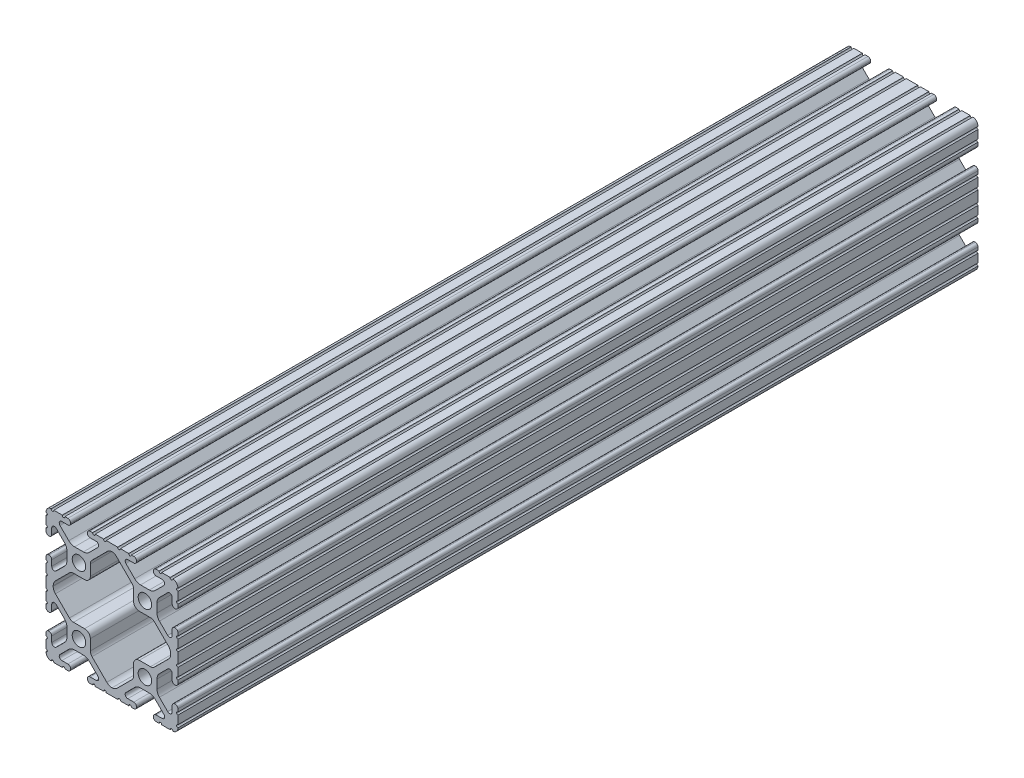
from build123d import *

# Parameters (mm, degrees)
SKETCH1_R      = 2.6035
EXTRUDE1_DEPTH = 308.102


with BuildPart() as part:
    # Sketch1 → Extrude1 (new body)
    with BuildSketch(Plane.XY):
        with BuildLine():
            Line((-2.210122516, -25.4), (2.210122516, -25.4))
            ThreePointArc((2.210122516, -25.4), (2.712319242, -24.815433371), (3.214515968, -25.4))
            Line((3.214515968, -25.4), (6.453532688, -25.4))
            ThreePointArc((6.453532688, -25.4), (6.955729414, -24.815433371), (7.45792614, -25.4))
            Line((7.45792614, -25.4), (8.405130016, -25.4))
            ThreePointArc((8.405130016, -25.4), (9.151169169, -25.100362415), (9.461500022, -24.358707602))
            Line((9.461500022, -24.358707602), (9.4615, -24.231492399))
            ThreePointArc((9.4615, -24.231492399), (9.151169155, -23.489837593), (8.405130016, -23.1902))
            Line((8.405130016, -23.1902), (6.087754002, -23.1902))
            ThreePointArc((6.087754002, -23.1902), (5.173448619, -22.579280675), (5.387974958, -21.500783941))
            Line((5.387974958, -21.500783941), (8.763022929, -18.12573597))
            ThreePointArc((8.763022929, -18.12573597), (9.793067061, -17.437482484), (11.008086959, -17.1958))
            Line((11.008086959, -17.1958), (14.391913041, -17.1958))
            ThreePointArc((14.391913041, -17.1958), (15.606932939, -17.437482484), (16.636977071, -18.12573597))
            Line((16.636977071, -18.12573597), (20.012025042, -21.500783941))
            ThreePointArc((20.012025042, -21.500783941), (20.223734168, -22.586011733), (19.297652818, -23.190092399))
            Line((19.297652818, -23.190092399), (16.9799, -23.190092399))
            ThreePointArc((16.9799, -23.190092399), (16.243518998, -23.495111397), (15.9385, -24.231492399))
            Line((15.9385, -24.231492399), (15.9385, -24.358492399))
            ThreePointArc((15.9385, -24.358492399), (16.248754204, -25.100286874), (16.994869984, -25.4))
            Line((16.994869984, -25.4), (18.134015685, -25.4))
            ThreePointArc((18.134015685, -25.4), (18.636212411, -24.815433371), (19.138409137, -25.4))
            Line((19.138409137, -25.4), (20.1295, -25.4))
            Line((20.1295, -25.4), (22.413213213, -25.4))
            ThreePointArc((22.413213213, -25.4), (22.915409939, -24.815433371), (23.417606664, -25.4))
            Line((23.417606664, -25.4), (23.450078724, -25.4))
            ThreePointArc((23.450078724, -25.4), (24.838729535, -24.730064765), (25.4, -23.294049529))
            Line((25.4, -23.294049529), (25.4, -23.268649529))
            ThreePointArc((25.4, -23.268649529), (24.892, -22.760649529), (25.4, -22.252649529))
            Line((25.4, -22.252649529), (25.4, -21.160449529))
            Line((25.4, -21.160449529), (25.4, -19.025239356))
            ThreePointArc((25.4, -19.025239356), (24.892, -18.517239356), (25.4, -18.009239356))
            Line((25.4, -18.009239356), (25.4, -16.91604181))
            ThreePointArc((25.4, -16.91604181), (25.094981002, -16.179660808), (24.3586, -15.87464181))
            Line((24.3586, -15.87464181), (24.2316, -15.87464181))
            ThreePointArc((24.2316, -15.87464181), (23.495218998, -16.179660808), (23.1902, -16.91604181))
            Line((23.1902, -16.91604181), (23.1902, -19.100988789))
            ThreePointArc((23.1902, -19.100988789), (22.563006367, -20.039650394), (21.45577951, -19.819409279))
            Line((21.45577951, -19.819409279), (18.27813597, -16.641765738))
            ThreePointArc((18.27813597, -16.641765738), (17.589882484, -15.611721606), (17.3482, -14.396701708))
            Line((17.3482, -14.396701708), (17.3482, -11.003495043))
            ThreePointArc((17.3482, -11.003495043), (17.590610762, -9.786718415), (18.280827, -8.755743204))
            Line((18.280827, -8.755743204), (21.45664064, -5.587529241))
            ThreePointArc((21.45664064, -5.587529241), (22.563568521, -5.368381274), (23.1902, -6.30680983))
            Line((23.1902, -6.30680983), (23.1902, -8.48395819))
            ThreePointArc((23.1902, -8.48395819), (23.495218998, -9.220339192), (24.2316, -9.52535819))
            Line((24.2316, -9.52535819), (24.3586, -9.52535819))
            ThreePointArc((24.3586, -9.52535819), (25.094981002, -9.220339192), (25.4, -8.48395819))
            Line((25.4, -8.48395819), (25.4, -7.327686685))
            ThreePointArc((25.4, -7.327686685), (24.892, -6.819686685), (25.4, -6.311686685))
            Line((25.4, -6.311686685), (25.4, -3.084276513))
            ThreePointArc((25.4, -3.084276513), (24.892, -2.576276513), (25.4, -2.068276513))
            Line((25.4, -2.068276513), (25.4, 2.068276513))
            ThreePointArc((25.4, 2.068276513), (24.892, 2.576276513), (25.4, 3.084276513))
            Line((25.4, 3.084276513), (25.4, 6.311686685))
            ThreePointArc((25.4, 6.311686685), (24.892, 6.819686685), (25.4, 7.327686685))
            Line((25.4, 7.327686685), (25.4, 8.48395819))
            ThreePointArc((25.4, 8.48395819), (25.094981002, 9.220339192), (24.3586, 9.52535819))
            Line((24.3586, 9.52535819), (24.2316, 9.52535819))
            ThreePointArc((24.2316, 9.52535819), (23.495218998, 9.220339192), (23.1902, 8.48395819))
            Line((23.1902, 8.48395819), (23.1902, 6.30680983))
            ThreePointArc((23.1902, 6.30680983), (22.563568521, 5.368381274), (21.45664064, 5.587529241))
            Line((21.45664064, 5.587529241), (18.280827, 8.755743204))
            ThreePointArc((18.280827, 8.755743204), (17.590610762, 9.786718415), (17.3482, 11.003495043))
            Line((17.3482, 11.003495043), (17.3482, 14.396701708))
            ThreePointArc((17.3482, 14.396701708), (17.589882484, 15.611721606), (18.27813597, 16.641765738))
            Line((18.27813597, 16.641765738), (21.45577951, 19.819409279))
            ThreePointArc((21.45577951, 19.819409279), (22.563006367, 20.039650394), (23.1902, 19.100988789))
            Line((23.1902, 19.100988789), (23.1902, 16.91604181))
            ThreePointArc((23.1902, 16.91604181), (23.495218998, 16.179660808), (24.2316, 15.87464181))
            Line((24.2316, 15.87464181), (24.3586, 15.87464181))
            ThreePointArc((24.3586, 15.87464181), (25.094981002, 16.179660808), (25.4, 16.91604181))
            Line((25.4, 16.91604181), (25.4, 18.009239356))
            ThreePointArc((25.4, 18.009239356), (24.892, 18.517239356), (25.4, 19.025239356))
            Line((25.4, 19.025239356), (25.4, 21.160449529))
            Line((25.4, 21.160449529), (25.4, 22.252649529))
            ThreePointArc((25.4, 22.252649529), (24.892, 22.760649529), (25.4, 23.268649529))
            Line((25.4, 23.268649529), (25.4, 23.294049529))
            ThreePointArc((25.4, 23.294049529), (24.838729535, 24.730064765), (23.450078724, 25.4))
            Line((23.450078724, 25.4), (23.417606664, 25.4))
            ThreePointArc((23.417606664, 25.4), (22.915409939, 24.815433371), (22.413213213, 25.4))
            Line((22.413213213, 25.4), (20.1295, 25.4))
            Line((20.1295, 25.4), (19.138409137, 25.4))
            ThreePointArc((19.138409137, 25.4), (18.636212411, 24.815433371), (18.134015685, 25.4))
            Line((18.134015685, 25.4), (16.994869984, 25.4))
            ThreePointArc((16.994869984, 25.4), (16.248754204, 25.100286874), (15.9385, 24.358492399))
            Line((15.9385, 24.358492399), (15.9385, 24.231492399))
            ThreePointArc((15.9385, 24.231492399), (16.243518998, 23.495111397), (16.9799, 23.190092399))
            Line((16.9799, 23.190092399), (19.297652818, 23.190092399))
            ThreePointArc((19.297652818, 23.190092399), (20.223734168, 22.586011733), (20.012025042, 21.500783941))
            Line((20.012025042, 21.500783941), (16.636977071, 18.12573597))
            ThreePointArc((16.636977071, 18.12573597), (15.606932939, 17.437482484), (14.391913041, 17.1958))
            Line((14.391913041, 17.1958), (11.008086959, 17.1958))
            ThreePointArc((11.008086959, 17.1958), (9.793067061, 17.437482484), (8.763022929, 18.12573597))
            Line((8.763022929, 18.12573597), (5.387974958, 21.500783941))
            ThreePointArc((5.387974958, 21.500783941), (5.173448619, 22.579280675), (6.087754002, 23.1902))
            Line((6.087754002, 23.1902), (8.405130016, 23.1902))
            ThreePointArc((8.405130016, 23.1902), (9.151169155, 23.489837593), (9.4615, 24.231492399))
            Line((9.4615, 24.231492399), (9.461500022, 24.358707602))
            ThreePointArc((9.461500022, 24.358707602), (9.151169169, 25.100362415), (8.405130016, 25.4))
            Line((8.405130016, 25.4), (7.45792614, 25.4))
            ThreePointArc((7.45792614, 25.4), (6.955729414, 24.815433371), (6.453532688, 25.4))
            Line((6.453532688, 25.4), (3.214515968, 25.4))
            ThreePointArc((3.214515968, 25.4), (2.712319242, 24.815433371), (2.210122516, 25.4))
            Line((2.210122516, 25.4), (-2.210122516, 25.4))
            ThreePointArc((-2.210122516, 25.4), (-2.712319242, 24.815433371), (-3.214515968, 25.4))
            Line((-3.214515968, 25.4), (-5.2705, 25.4))
            Line((-5.2705, 25.4), (-6.453532688, 25.4))
            ThreePointArc((-6.453532688, 25.4), (-6.955729414, 24.815433371), (-7.45792614, 25.4))
            Line((-7.45792614, 25.4), (-8.405130016, 25.4))
            ThreePointArc((-8.405130016, 25.4), (-9.151169169, 25.100362415), (-9.461500022, 24.358707602))
            Line((-9.461500022, 24.358707602), (-9.4615, 24.231492399))
            ThreePointArc((-9.4615, 24.231492399), (-9.151169155, 23.489837593), (-8.405130016, 23.1902))
            Line((-8.405130016, 23.1902), (-6.087754002, 23.1902))
            ThreePointArc((-6.087754002, 23.1902), (-5.173448619, 22.579280675), (-5.387974958, 21.500783941))
            Line((-5.387974958, 21.500783941), (-8.763022929, 18.12573597))
            ThreePointArc((-8.763022929, 18.12573597), (-9.793067061, 17.437482484), (-11.008086959, 17.1958))
            Line((-11.008086959, 17.1958), (-14.391913041, 17.1958))
            ThreePointArc((-14.391913041, 17.1958), (-15.606932939, 17.437482484), (-16.636977071, 18.12573597))
            Line((-16.636977071, 18.12573597), (-20.012025042, 21.500783941))
            ThreePointArc((-20.012025042, 21.500783941), (-20.223734168, 22.586011733), (-19.297652818, 23.190092399))
            Line((-19.297652818, 23.190092399), (-16.9799, 23.190092399))
            ThreePointArc((-16.9799, 23.190092399), (-16.243518998, 23.495111397), (-15.9385, 24.231492399))
            Line((-15.9385, 24.231492399), (-15.9385, 24.358492399))
            ThreePointArc((-15.9385, 24.358492399), (-16.248754204, 25.100286874), (-16.994869984, 25.4))
            Line((-16.994869984, 25.4), (-18.134015685, 25.4))
            ThreePointArc((-18.134015685, 25.4), (-18.636212411, 24.815433371), (-19.138409137, 25.4))
            Line((-19.138409137, 25.4), (-20.1295, 25.4))
            Line((-20.1295, 25.4), (-22.413213213, 25.4))
            ThreePointArc((-22.413213213, 25.4), (-22.915409939, 24.815433371), (-23.417606664, 25.4))
            Line((-23.417606664, 25.4), (-23.450078724, 25.4))
            ThreePointArc((-23.450078724, 25.4), (-24.838729535, 24.730064765), (-25.4, 23.294049529))
            Line((-25.4, 23.294049529), (-25.4, 23.268649529))
            ThreePointArc((-25.4, 23.268649529), (-24.892, 22.760649529), (-25.4, 22.252649529))
            Line((-25.4, 22.252649529), (-25.4, 21.160449529))
            Line((-25.4, 21.160449529), (-25.4, 19.025239356))
            ThreePointArc((-25.4, 19.025239356), (-24.892, 18.517239356), (-25.4, 18.009239356))
            Line((-25.4, 18.009239356), (-25.4, 16.91604181))
            ThreePointArc((-25.4, 16.91604181), (-25.094981002, 16.179660808), (-24.3586, 15.87464181))
            Line((-24.3586, 15.87464181), (-24.2316, 15.87464181))
            ThreePointArc((-24.2316, 15.87464181), (-23.495218998, 16.179660808), (-23.1902, 16.91604181))
            Line((-23.1902, 16.91604181), (-23.1902, 19.100988789))
            ThreePointArc((-23.1902, 19.100988789), (-22.563006367, 20.039650394), (-21.45577951, 19.819409279))
            Line((-21.45577951, 19.819409279), (-18.27813597, 16.641765738))
            ThreePointArc((-18.27813597, 16.641765738), (-17.589882484, 15.611721606), (-17.3482, 14.396701708))
            Line((-17.3482, 14.396701708), (-17.3482, 11.003495043))
            ThreePointArc((-17.3482, 11.003495043), (-17.590610762, 9.786718415), (-18.280827, 8.755743204))
            Line((-18.280827, 8.755743204), (-21.45664064, 5.587529241))
            ThreePointArc((-21.45664064, 5.587529241), (-22.563568521, 5.368381274), (-23.1902, 6.30680983))
            Line((-23.1902, 6.30680983), (-23.1902, 8.48395819))
            ThreePointArc((-23.1902, 8.48395819), (-23.495218998, 9.220339192), (-24.2316, 9.52535819))
            Line((-24.2316, 9.52535819), (-24.3586, 9.52535819))
            ThreePointArc((-24.3586, 9.52535819), (-25.094981002, 9.220339192), (-25.4, 8.48395819))
            Line((-25.4, 8.48395819), (-25.4, 7.327686685))
            ThreePointArc((-25.4, 7.327686685), (-24.892, 6.819686685), (-25.4, 6.311686685))
            Line((-25.4, 6.311686685), (-25.4, 3.084276513))
            ThreePointArc((-25.4, 3.084276513), (-24.892, 2.576276513), (-25.4, 2.068276513))
            Line((-25.4, 2.068276513), (-25.4, -2.068276513))
            ThreePointArc((-25.4, -2.068276513), (-24.892, -2.576276513), (-25.4, -3.084276513))
            Line((-25.4, -3.084276513), (-25.4, -4.176476513))
            Line((-25.4, -4.176476513), (-25.4, -6.311686685))
            ThreePointArc((-25.4, -6.311686685), (-24.892, -6.819686685), (-25.4, -7.327686685))
            Line((-25.4, -7.327686685), (-25.4, -8.48395819))
            ThreePointArc((-25.4, -8.48395819), (-25.094981002, -9.220339192), (-24.3586, -9.52535819))
            Line((-24.3586, -9.52535819), (-24.2316, -9.52535819))
            ThreePointArc((-24.2316, -9.52535819), (-23.495218998, -9.220339192), (-23.1902, -8.48395819))
            Line((-23.1902, -8.48395819), (-23.1902, -6.30680983))
            ThreePointArc((-23.1902, -6.30680983), (-22.563568521, -5.368381274), (-21.45664064, -5.587529241))
            Line((-21.45664064, -5.587529241), (-18.280827, -8.755743204))
            ThreePointArc((-18.280827, -8.755743204), (-17.590610762, -9.786718415), (-17.3482, -11.003495043))
            Line((-17.3482, -11.003495043), (-17.3482, -14.396701708))
            ThreePointArc((-17.3482, -14.396701708), (-17.589882484, -15.611721606), (-18.27813597, -16.641765738))
            Line((-18.27813597, -16.641765738), (-21.45577951, -19.819409279))
            ThreePointArc((-21.45577951, -19.819409279), (-22.563006367, -20.039650394), (-23.1902, -19.100988789))
            Line((-23.1902, -19.100988789), (-23.1902, -16.91604181))
            ThreePointArc((-23.1902, -16.91604181), (-23.495218998, -16.179660808), (-24.2316, -15.87464181))
            Line((-24.2316, -15.87464181), (-24.3586, -15.87464181))
            ThreePointArc((-24.3586, -15.87464181), (-25.094981002, -16.179660808), (-25.4, -16.91604181))
            Line((-25.4, -16.91604181), (-25.4, -18.009239356))
            ThreePointArc((-25.4, -18.009239356), (-24.892, -18.517239356), (-25.4, -19.025239356))
            Line((-25.4, -19.025239356), (-25.4, -21.160449529))
            Line((-25.4, -21.160449529), (-25.4, -22.252649529))
            ThreePointArc((-25.4, -22.252649529), (-24.892, -22.760649529), (-25.4, -23.268649529))
            Line((-25.4, -23.268649529), (-25.4, -23.294049529))
            ThreePointArc((-25.4, -23.294049529), (-24.838729535, -24.730064765), (-23.450078724, -25.4))
            Line((-23.450078724, -25.4), (-23.417606664, -25.4))
            ThreePointArc((-23.417606664, -25.4), (-22.915409939, -24.815433371), (-22.413213213, -25.4))
            Line((-22.413213213, -25.4), (-20.1295, -25.4))
            Line((-20.1295, -25.4), (-19.138409137, -25.4))
            ThreePointArc((-19.138409137, -25.4), (-18.636212411, -24.815433371), (-18.134015685, -25.4))
            Line((-18.134015685, -25.4), (-16.994869984, -25.4))
            ThreePointArc((-16.994869984, -25.4), (-16.248754204, -25.100286874), (-15.9385, -24.358492399))
            Line((-15.9385, -24.358492399), (-15.9385, -24.231492399))
            ThreePointArc((-15.9385, -24.231492399), (-16.243518998, -23.495111397), (-16.9799, -23.190092399))
            Line((-16.9799, -23.190092399), (-19.297652818, -23.190092399))
            ThreePointArc((-19.297652818, -23.190092399), (-20.223734168, -22.586011733), (-20.012025042, -21.500783941))
            Line((-20.012025042, -21.500783941), (-16.636977071, -18.12573597))
            ThreePointArc((-16.636977071, -18.12573597), (-15.606932939, -17.437482484), (-14.391913041, -17.1958))
            Line((-14.391913041, -17.1958), (-11.008086959, -17.1958))
            ThreePointArc((-11.008086959, -17.1958), (-9.793067061, -17.437482484), (-8.763022929, -18.12573597))
            Line((-8.763022929, -18.12573597), (-5.387974958, -21.500783941))
            ThreePointArc((-5.387974958, -21.500783941), (-5.173448619, -22.579280675), (-6.087754002, -23.1902))
            Line((-6.087754002, -23.1902), (-8.405130016, -23.1902))
            ThreePointArc((-8.405130016, -23.1902), (-9.151169155, -23.489837593), (-9.4615, -24.231492399))
            Line((-9.4615, -24.231492399), (-9.461500022, -24.358707602))
            ThreePointArc((-9.461500022, -24.358707602), (-9.151169169, -25.100362415), (-8.405130016, -25.4))
            Line((-8.405130016, -25.4), (-7.45792614, -25.4))
            ThreePointArc((-7.45792614, -25.4), (-6.955729414, -24.815433371), (-6.453532688, -25.4))
            Line((-6.453532688, -25.4), (-5.2705, -25.4))
            Line((-5.2705, -25.4), (-3.214515968, -25.4))
            ThreePointArc((-3.214515968, -25.4), (-2.712319242, -24.815433371), (-2.210122516, -25.4))
        make_face()
        with Locations((12.7, -12.7)):
            Circle(SKETCH1_R, mode=Mode.SUBTRACT)
        with Locations((-12.7, -12.7)):
            Circle(SKETCH1_R, mode=Mode.SUBTRACT)
        with Locations((-12.7, 12.7)):
            Circle(SKETCH1_R, mode=Mode.SUBTRACT)
        with Locations((12.7, 12.7)):
            Circle(SKETCH1_R, mode=Mode.SUBTRACT)
        with BuildLine():
            Line((-1.987770861, -21.775858908), (-7.683964565, -16.079665203))
            ThreePointArc((-7.683964565, -16.079665203), (-8.162988991, -15.362754487), (-8.3312, -14.517100638))
            Line((-8.3312, -14.517100638), (-8.3312, -10.3886))
            ThreePointArc((-8.3312, -10.3886), (-8.978435435, -8.826035435), (-10.541, -8.1788))
            Line((-10.541, -8.1788), (-14.816495758, -8.1788))
            ThreePointArc((-14.816495758, -8.1788), (-15.66092662, -8.01109514), (-16.377187366, -7.53343528))
            Line((-16.377187366, -7.53343528), (-21.77338316, -2.150152507))
            ThreePointArc((-21.77338316, -2.150152507), (-22.408382099, -1.201655313), (-22.6314, -0.082220815))
            Line((-22.6314, -0.082220815), (-22.6314, 0.082220815))
            ThreePointArc((-22.6314, 0.082220815), (-22.408382099, 1.201655313), (-21.77338316, 2.150152507))
            Line((-21.77338316, 2.150152507), (-16.377187366, 7.53343528))
            ThreePointArc((-16.377187366, 7.53343528), (-15.66092662, 8.01109514), (-14.816495758, 8.1788))
            Line((-14.816495758, 8.1788), (-10.541, 8.1788))
            ThreePointArc((-10.541, 8.1788), (-8.978435435, 8.826035435), (-8.3312, 10.3886))
            Line((-8.3312, 10.3886), (-8.3312, 14.517100638))
            ThreePointArc((-8.3312, 14.517100638), (-8.162988991, 15.362754487), (-7.683964565, 16.079665203))
            Line((-7.683964565, 16.079665203), (-1.795557487, 21.968072281))
            ThreePointArc((-1.795557487, 21.968072281), (-0.97153248, 22.546678968), (0, 22.811117151))
            ThreePointArc((0, 22.811117151), (0.97153248, 22.546678968), (1.795557487, 21.968072281))
            Line((1.795557487, 21.968072281), (7.683964565, 16.079665203))
            ThreePointArc((7.683964565, 16.079665203), (8.162988991, 15.362754487), (8.3312, 14.517100638))
            Line((8.3312, 14.517100638), (8.3312, 12.700098375))
            Line((8.3312, 12.700098375), (8.3312, 10.389032234))
            ThreePointArc((8.3312, 10.389032234), (8.978435435, 8.826467669), (10.541, 8.179232234))
            Line((10.541, 8.179232234), (14.816062488, 8.179232234))
            ThreePointArc((14.816062488, 8.179232234), (15.660493349, 8.011527374), (16.376754096, 7.533867514))
            Line((16.376754096, 7.533867514), (21.77338316, 2.150152507))
            ThreePointArc((21.77338316, 2.150152507), (22.408382099, 1.201655313), (22.6314, 0.082220815))
            Line((22.6314, 0.082220815), (22.6314, -0.082220815))
            ThreePointArc((22.6314, -0.082220815), (22.408382099, -1.201655313), (21.77338316, -2.150152507))
            Line((21.77338316, -2.150152507), (16.377187366, -7.53343528))
            ThreePointArc((16.377187366, -7.53343528), (15.66092662, -8.01109514), (14.816495758, -8.1788))
            Line((14.816495758, -8.1788), (10.541, -8.1788))
            ThreePointArc((10.541, -8.1788), (8.978435435, -8.826035435), (8.3312, -10.3886))
            Line((8.3312, -10.3886), (8.3312, -14.517100638))
            ThreePointArc((8.3312, -14.517100638), (8.162988991, -15.362754487), (7.683964565, -16.079665203))
            Line((7.683964565, -16.079665203), (1.987770861, -21.775858908))
            ThreePointArc((1.987770861, -21.775858908), (1.075921771, -22.393947165), (0, -22.630366707))
            ThreePointArc((0, -22.630366707), (-1.075921771, -22.393947165), (-1.987770861, -21.775858908))
        make_face(mode=Mode.SUBTRACT)
    extrude(amount=-EXTRUDE1_DEPTH)


solid = part.part
